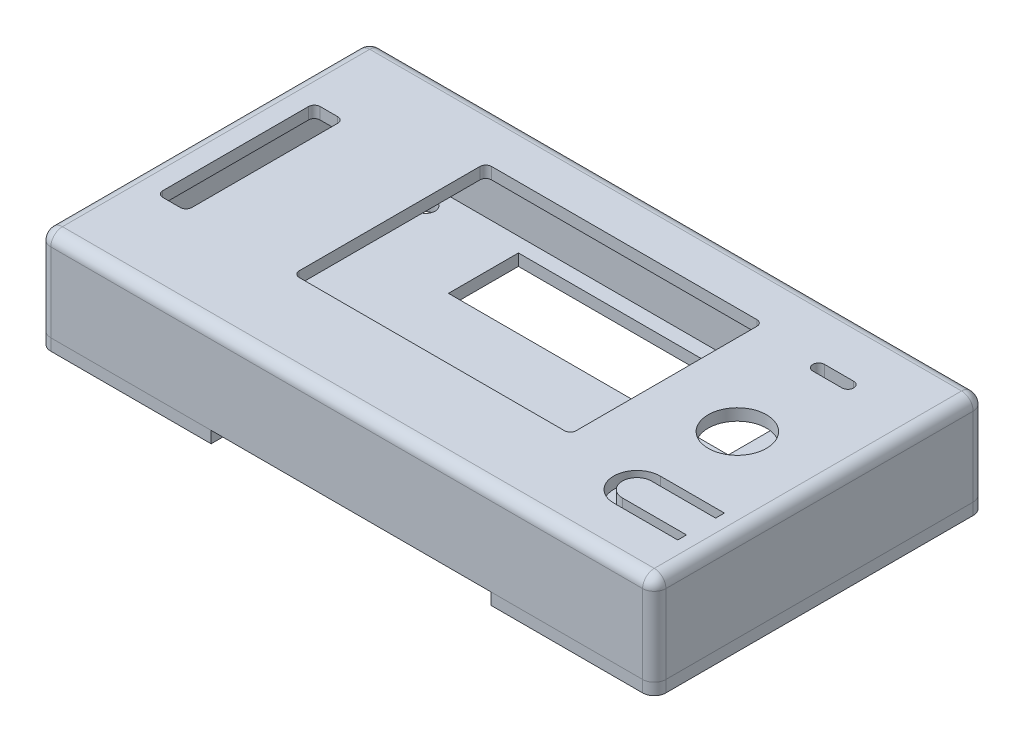
from build123d import *

# Parameters (mm, degrees)
CROQUIS1_W               = 105.5
CROQUIS1_H               = 56.7
CROQUIS1_R               = 5
CROQUIS1_W_2             = 47.5
CROQUIS1_H_2             = 33
CROQUIS1_W_3             = 5
CROQUIS1_H_3             = 27
SALIENTE_EXTRUIR1_DEPTH  = 2
CROQUIS5_W               = 105.5
CROQUIS5_H               = 56.7
CROQUIS5_W_2             = 102.5
CROQUIS5_H_2             = 53.7
SALIENTE_EXTRUIR4_DEPTH  = 13.5
CROQUIS6_R               = 1.6
CROQUIS6_R_2             = 1.55
CROQUIS6_W               = 7
CROQUIS6_H               = 45
CROQUIS6_W_2             = 48
CROQUIS6_H_2             = 12
SALIENTE_EXTRUIR5_DEPTH  = 2
CROQUIS8_W               = 6.15
CROQUIS8_H               = 7
SALIENTE_EXTRUIR13_DEPTH = 9
CROQUIS9_R               = 2.15
CORTAR_EXTRUIR2_DEPTH    = 3.5
REDONDEO4_R              = 2
REDONDEO6_R              = 1
REDONDEO7_R              = 1
CROQUIS10_R              = 2.5
SALIENTE_EXTRUIR14_DEPTH = 2


with BuildPart() as part:
    # Croquis1 → Saliente-Extruir1 (new body)
    with BuildSketch(Plane(origin=(0, 0, 0), x_dir=(1, 0, 0), z_dir=(0, 1, 0))):
        with Locations((50.5, 26.1)):
            Rectangle(CROQUIS1_W, CROQUIS1_H)
        with Locations((88.05, 27.2)):
            Circle(CROQUIS1_R, mode=Mode.SUBTRACT)
        with Locations((50.35, 29)):
            Rectangle(CROQUIS1_W_2, CROQUIS1_H_2, mode=Mode.SUBTRACT)
        with Locations((5.5, 26.2)):
            Rectangle(CROQUIS1_W_3, CROQUIS1_H_3, mode=Mode.SUBTRACT)
        with BuildLine():
            Line((88.05, 12.48), (99.05, 12.48))
            Line((99.05, 12.48), (99.05, 13.98))
            Line((99.05, 13.98), (88.05, 13.98))
            ThreePointArc((88.05, 13.98), (84.05, 9.98), (88.05, 5.98))
            Line((88.05, 5.98), (99.05, 5.98))
            Line((99.05, 5.98), (99.05, 7.48))
            Line((99.05, 7.48), (88.05, 7.48))
            ThreePointArc((88.05, 7.48), (85.55, 9.98), (88.05, 12.48))
        make_face(mode=Mode.SUBTRACT)
        with BuildLine():
            Line((90.55, 42.65), (85.55, 42.65))
            ThreePointArc((85.55, 42.65), (84.55, 43.65), (85.55, 44.65))
            Line((85.55, 44.65), (90.55, 44.65))
            ThreePointArc((90.55, 44.65), (91.55, 43.65), (90.55, 42.65))
        make_face(mode=Mode.SUBTRACT)
    extrude(amount=SALIENTE_EXTRUIR1_DEPTH)

    # Croquis5 → Saliente-Extruir4 (add)
    with BuildSketch(Plane.XZ):
        with Locations((50.5, -26.1)):
            Rectangle(CROQUIS5_W, CROQUIS5_H)
        with Locations((50.5, -26.1)):
            Rectangle(CROQUIS5_W_2, CROQUIS5_H_2, mode=Mode.SUBTRACT)
    extrude(amount=SALIENTE_EXTRUIR4_DEPTH)

    # Croquis6 → Saliente-Extruir5 (add)
    with BuildSketch(Plane.XZ.offset(13.5)):
        Polygon((103.25, 2.25), (103.25, -54.45), (-2.25, -54.45), (-2.25, 2.25), (27.25, 2.25), (27.25, -3.75), (75.25, -3.75), (75.25, 2.25), align=None)
        with Locations((12.3, -49.5)):
            Circle(CROQUIS6_R, mode=Mode.SUBTRACT)
        with Locations((98.3, -2.7)):
            Circle(CROQUIS6_R, mode=Mode.SUBTRACT)
        with Locations((98.3, -49.5)):
            Circle(CROQUIS6_R, mode=Mode.SUBTRACT)
        with Locations((12.3, -2.7)):
            Circle(CROQUIS6_R, mode=Mode.SUBTRACT)
        with Locations((80.5, -26.1)):
            Circle(CROQUIS6_R_2, mode=Mode.SUBTRACT)
        with Locations((20.5, -26.1)):
            Circle(CROQUIS6_R_2, mode=Mode.SUBTRACT)
        with Locations((5.95, -26.45)):
            Rectangle(CROQUIS6_W, CROQUIS6_H, mode=Mode.SUBTRACT)
        with Locations((51.25, -44.45)):
            Rectangle(CROQUIS6_W_2, CROQUIS6_H_2, mode=Mode.SUBTRACT)
    extrude(amount=SALIENTE_EXTRUIR5_DEPTH)

    # Croquis8 → Saliente-Extruir13 (add)
    with BuildSketch(Plane.XZ):
        with Locations((12.3, -2.75)):
            Rectangle(CROQUIS8_W, CROQUIS8_H)
        with Locations((98.675, -2.75)):
            Rectangle(CROQUIS8_W, CROQUIS8_H)
        with Locations((12.3, -49.45)):
            Rectangle(CROQUIS8_W, CROQUIS8_H)
        with Locations((98.675, -49.45)):
            Rectangle(CROQUIS8_W, CROQUIS8_H)
    extrude(amount=SALIENTE_EXTRUIR13_DEPTH)

    # Croquis9 → Cortar-Extruir2 (cut)
    with BuildSketch(Plane.XZ.offset(9)):
        with Locations((12.3, -2.7)):
            Circle(CROQUIS9_R)
        with Locations((98.3, -2.7)):
            Circle(CROQUIS9_R)
        with Locations((98.3, -49.5)):
            Circle(CROQUIS9_R)
        with Locations((12.3, -49.5)):
            Circle(CROQUIS9_R)
    extrude(amount=-CORTAR_EXTRUIR2_DEPTH, mode=Mode.SUBTRACT)

    # Redondeo4
    redondeo4_edges = [part.edges().sort_by_distance(p)[0] for p in [
        (103.25, 2, -26.1),
        (50.5, 2, -54.45),
        (-2.25, 2, -26.1),
        (50.5, 2, 2.25),
        (-2.25, -6.75, -54.45),
        (103.25, -6.75, -54.45),
        (103.25, -6.75, 2.25),
        (-2.25, -6.75, 2.25),
    ]]
    fillet(redondeo4_edges, radius=REDONDEO4_R)


with BuildPart() as body_2:
    # Partir1: the piece on the far side of the plane
    add(part.part)
    split(bisect_by=Plane(origin=(0, -13.5, 0), x_dir=(0, 0, -1), z_dir=(0, -1, 0)), keep=Keep.BOTTOM)

    # Redondeo6
    redondeo6_edges = [body_2.edges().sort_by_distance(p)[0] for p in [
        (3, 1, -39.7),
        (8, 1, -39.7),
        (8, 1, -12.7),
        (3, 1, -12.7),
        (26.6, 1, -45.5),
        (74.1, 1, -45.5),
        (74.1, 1, -12.5),
        (26.6, 1, -12.5),
    ]]
    fillet(redondeo6_edges, radius=REDONDEO6_R)

    # Redondeo7
    redondeo7_edges = [body_2.edges().sort_by_distance(p)[0] for p in [
        (95.6, 0, -2.615),
        (100.4, 0, -6.25),
        (101.75, -4.5, -6.25),
        (95.6, -4.5, 0.75),
        (98.675, 0, -45.95),
        (95.6, 0, -49.45),
        (95.6, -4.5, -52.95),
        (101.75, -4.5, -45.95),
        (9.225, 0, -49.45),
        (15.375, 0, -49.45),
        (12.3, 0, -45.95),
        (15.375, -4.5, -52.95),
        (9.225, -4.5, -52.95),
        (9.225, 0, -2.75),
        (12.3, 0, -6.25),
        (15.375, 0, -2.75),
        (15.375, -4.5, 0.75),
        (9.225, -4.5, 0.75),
    ]]
    fillet(redondeo7_edges, radius=REDONDEO7_R)

    # Croquis10 → Saliente-Extruir14 (add)
    with BuildSketch(Plane.XZ):
        with Locations((88.05, -9.98)):
            Circle(CROQUIS10_R)
    extrude(amount=SALIENTE_EXTRUIR14_DEPTH)


with BuildPart() as part_1:
    add(part.part)

    # Partir1
    split(bisect_by=Plane(origin=(0, -13.5, 0), x_dir=(0, 0, -1), z_dir=(0, -1, 0)), keep=Keep.TOP)


solid = Compound([body_2.part, part_1.part])
